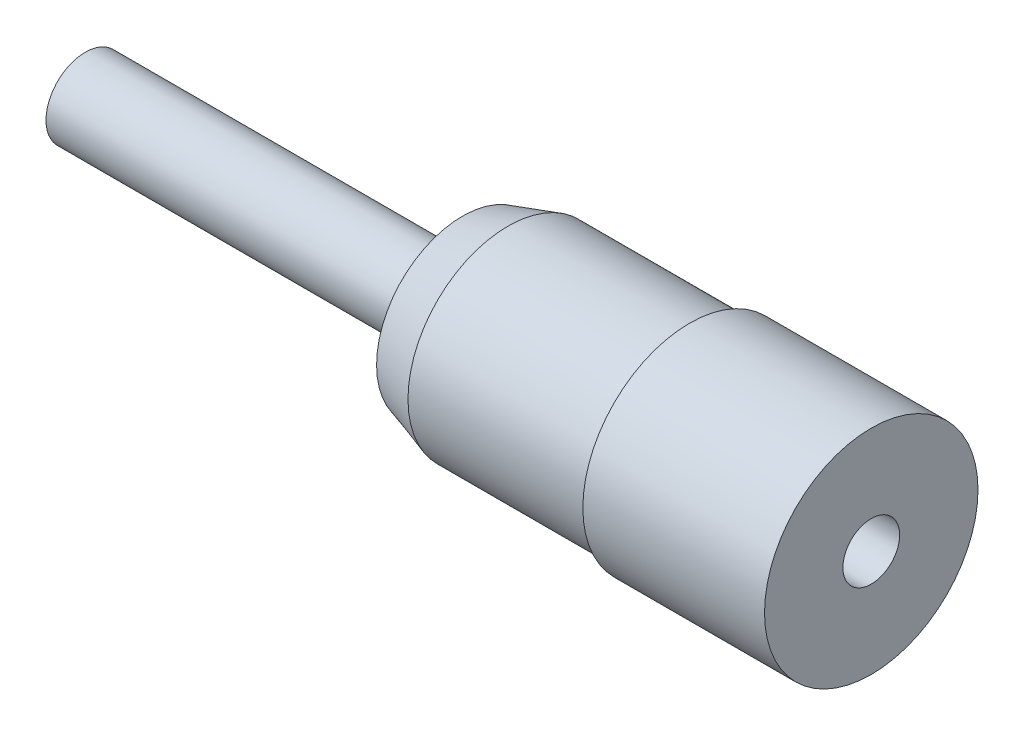
from build123d import *

# Parameters (mm, degrees)
TAP_DRILL_FOR_M3_TAP1_D     = 2.5
TAP_DRILL_FOR_M3_TAP1_DEPTH = 5.5
TAP_DRILL_FOR_M3_TAP1_TIP   = 0.751075774


with BuildPart() as part:
    # Sketch2 → Revolve4 (revolve)
    with BuildSketch(Plane.XY):
        Polygon((296.055680528, 81.106851928), (303.855680528, 81.106851928), (304.055680528, 81.406851928), (312.055680528, 81.406851928), (312.055680528, 79.406851928), (312.055680528, 76.706851928), (277.446915198, 76.706851928), (277.446915198, 78.436851928), (294.046915198, 78.436851928), (309.446915198, 78.436851928), (309.446915198, 81.106851928), (304.216235656, 81.106851928), (304.016235656, 80.806851928), (296.100980113, 80.806851928), (294.055680528, 80.174765167), (294.055680528, 80.488764715), align=None)
    revolve(axis=Axis((277.446915198, 76.706851928, 0), (1, 0, 0)))

    # Tap Drill for M3 Tap1
    with Locations(Plane(origin=(312.055680528, 0, 0), x_dir=(0, 0, -1), z_dir=(1, 0, 0))):
        with Locations((0, 76.706851928)):
            Hole(TAP_DRILL_FOR_M3_TAP1_D / 2, depth=TAP_DRILL_FOR_M3_TAP1_DEPTH)
            with Locations((0, 0, -(TAP_DRILL_FOR_M3_TAP1_DEPTH + TAP_DRILL_FOR_M3_TAP1_TIP / 2))):  # 118° drill point
                Cone(0, TAP_DRILL_FOR_M3_TAP1_D / 2, TAP_DRILL_FOR_M3_TAP1_TIP, mode=Mode.SUBTRACT)


solid = part.part
